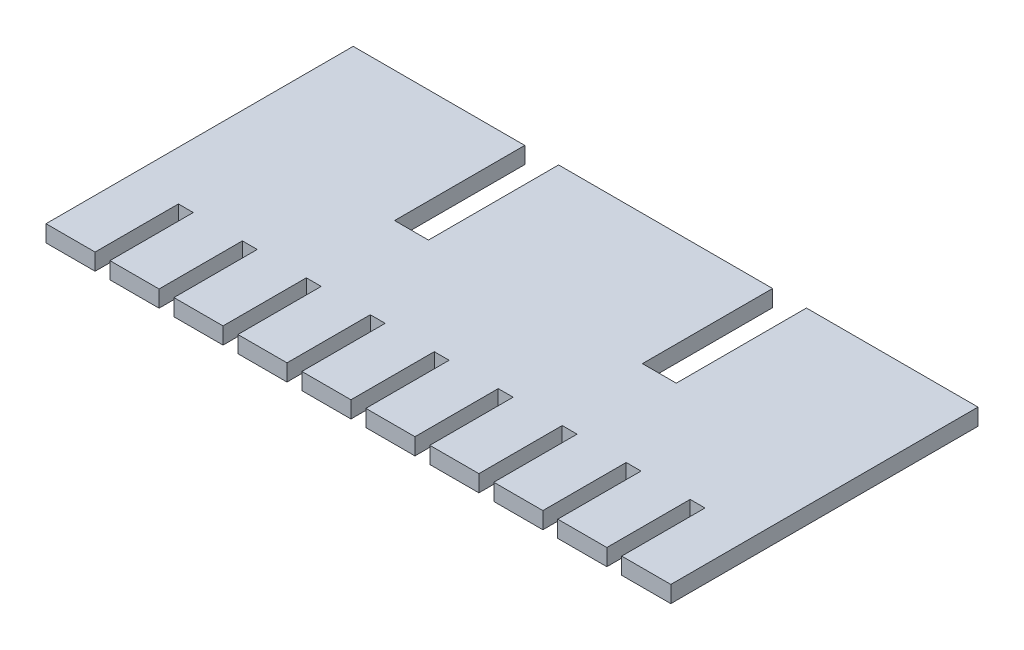
from build123d import *

# Parameters (mm, degrees)
BOSS_EXTRUDE3_DEPTH = 1.6


with BuildPart() as part:
    # Sketch1 → Boss-Extrude3 (new body)
    with BuildSketch(Plane(origin=(0, 0, 0), x_dir=(1, 0, 0), z_dir=(0, 1, 0))):
        Polygon((0, 0), (0, -29.5), (4.7139, -29.5), (4.7139, -21.5), (6.1429, -21.5), (6.1429, -29.5), (10.8568, -29.5), (10.8568, -21.5), (12.2858, -21.5), (12.2858, -29.5), (16.9997, -29.5), (16.9997, -21.5), (18.4287, -21.5), (18.4287, -29.5), (23.1426, -29.5), (23.1426, -21.5), (24.5716, -21.5), (24.5716, -29.5), (29.2855, -29.5), (29.2855, -21.5), (30.7145, -21.5), (30.7145, -29.5), (35.4284, -29.5), (35.4284, -21.5), (36.8574, -21.5), (36.8574, -29.5), (41.5713, -29.5), (41.5713, -21.5), (43.0003, -21.5), (43.0003, -29.5), (47.7142, -29.5), (47.7142, -21.5), (49.1432, -21.5), (49.1432, -29.5), (53.8571, -29.5), (53.8571, -21.5), (55.2861, -21.5), (55.2861, -29.5), (60, -29.5), (60, 0), (43.525, 0), (43.525, -12.5), (40.275, -12.5), (40.275, 0), (19.725, 0), (19.725, -12.5), (16.475, -12.5), (16.475, 0), align=None)
    extrude(amount=BOSS_EXTRUDE3_DEPTH)


solid = part.part
